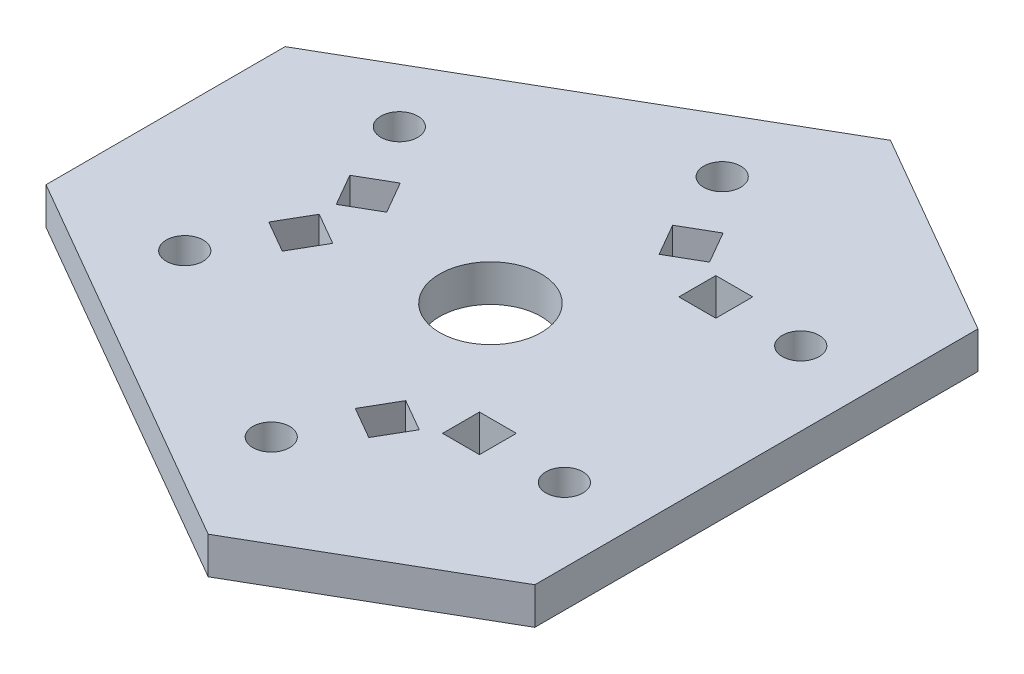
from build123d import *

# Parameters (mm, degrees)
SKETCH2_R           = 1.5875
SKETCH2_R_2         = 4.365625
SKETCH2_W           = 3.175
SKETCH2_H           = 3.175
BOSS_EXTRUDE2_DEPTH = 3.175


with BuildPart() as part:
    # Sketch2 → Boss-Extrude2 (new body)
    with BuildSketch(Plane(origin=(0, 0, 0), x_dir=(1, 0, 0), z_dir=(0, 1, 0))):
        Polygon((22.868144039, 19.05), (22.868144039, -19.05), (5.063711923, -29.329393675), (-27.931855961, -10.279393675), (-27.931855961, 10.279393675), (5.063711923, 29.329393675), align=None)
        with Locations((16.518144039, 10.16)):
            Circle(SKETCH2_R, mode=Mode.SUBTRACT)
        with Locations((16.518144039, -10.16)):
            Circle(SKETCH2_R, mode=Mode.SUBTRACT)
        with Locations((0.539746083, -19.385132361)):
            Circle(SKETCH2_R, mode=Mode.SUBTRACT)
        Circle(SKETCH2_R_2, mode=Mode.SUBTRACT)
        with Locations((-17.057890122, -9.225132361)):
            Circle(SKETCH2_R, mode=Mode.SUBTRACT)
        with Locations((-17.057890122, 9.225132361)):
            Circle(SKETCH2_R, mode=Mode.SUBTRACT)
        with Locations((0.539746083, 19.385132361)):
            Circle(SKETCH2_R, mode=Mode.SUBTRACT)
        with Locations((9.215644039, 10.16)):
            Rectangle(SKETCH2_W, SKETCH2_H, mode=Mode.SUBTRACT)
        with Locations((9.215644039, -10.16)):
            Rectangle(SKETCH2_W, SKETCH2_H, mode=Mode.SUBTRACT)
        Polygon((3.609930755, -10.892416521), (2.022430755, -13.642047178), (4.772061412, -15.229547178), (6.359561412, -12.479916521), align=None, mode=Mode.SUBTRACT)
        Polygon((-11.238074793, -2.319916521), (-12.825574793, -5.069547178), (-15.57520545, -3.482047178), (-13.98770545, -0.732416521), align=None, mode=Mode.SUBTRACT)
        Polygon((-11.238074793, 2.319916521), (-12.825574793, 5.069547178), (-15.57520545, 3.482047178), (-13.98770545, 0.732416521), align=None, mode=Mode.SUBTRACT)
        Polygon((3.609930755, 10.892416521), (2.022430755, 13.642047178), (4.772061412, 15.229547178), (6.359561412, 12.479916521), align=None, mode=Mode.SUBTRACT)
    extrude(amount=BOSS_EXTRUDE2_DEPTH)


solid = part.part
